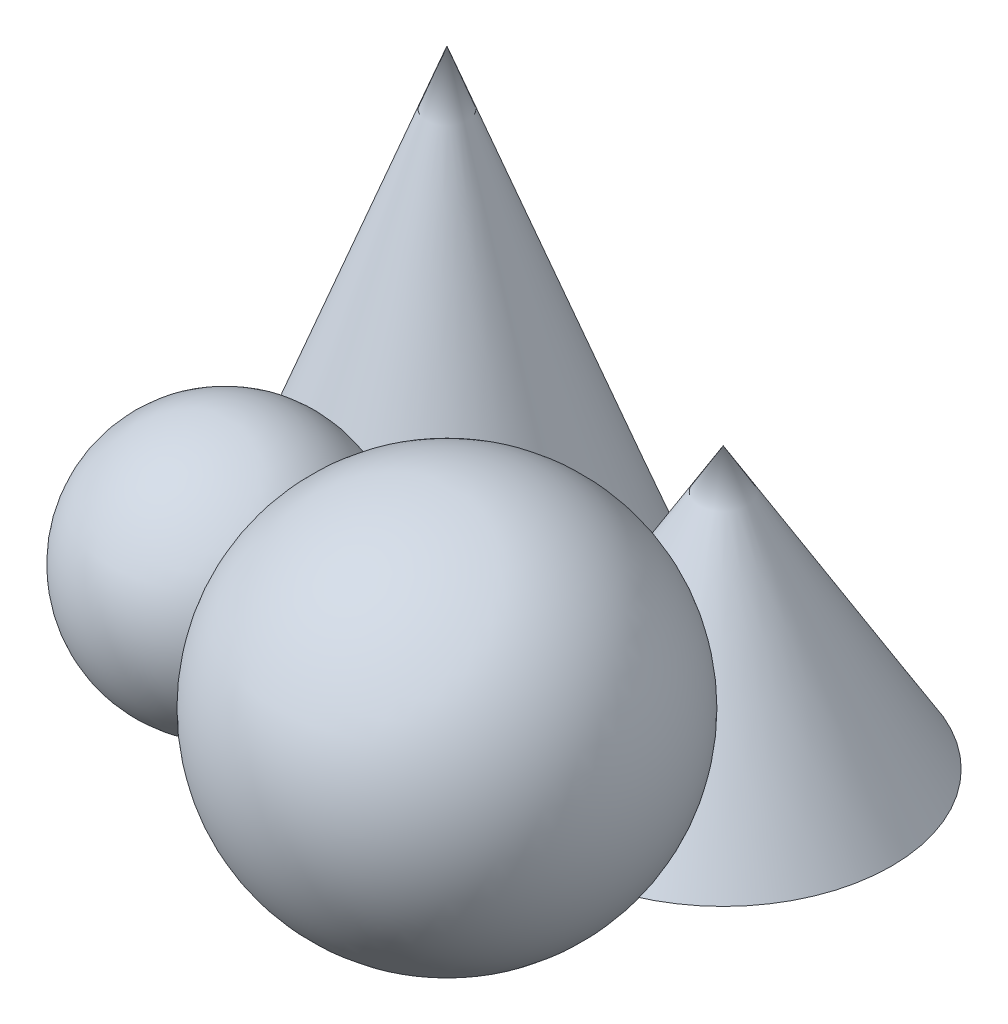
from build123d import *

# Parameters (mm, degrees)
SKETCH1_R = 30
SKETCH4_R = 30.84690874


with BuildPart() as part:
    # Sketch1 → ConeB section 0
    with BuildSketch(Plane(origin=(0, 0, 0), x_dir=(1, 0, 0), z_dir=(0, 1, 0)), mode=Mode.PRIVATE) as coneb_s0:
        Circle(SKETCH1_R)
    loft([Vertex(0, 80, 0), coneb_s0.sketch])


with BuildPart() as body_2:
    # Sketch3 → SphereA (revolve)
    with BuildSketch(Plane.XY.offset(60.1040764)):
        with BuildLine():
            Line((60.1040764, 70), (60.1040764, 0))
            ThreePointArc((60.1040764, 0), (95.1040764, 35), (60.1040764, 70))
        make_face()
    revolve(axis=Axis((60.1040764, 70, 60.1040764), (0, -1, 0)))


with BuildPart() as body_3:
    # Sketch4 → ConeD section 0
    with BuildSketch(Plane(origin=(0, 0, 0), x_dir=(1, 0, 0), z_dir=(0, 1, 0)), mode=Mode.PRIVATE) as coned_s0:
        with Locations((60.1040764, -9.45621576)):
            Circle(SKETCH4_R)
    loft([coned_s0.sketch, Vertex(60.1040764, 51.33236066, 9.45621576)])


with BuildPart() as body_4:
    # Sketch6 → SphereC (revolve)
    with BuildSketch(Plane.XY.offset(45.74120625)):
        with BuildLine():
            Line((5.05797364, 46.23375526), (5.05797364, 0))
            ThreePointArc((5.05797364, 0), (28.17485127, 23.11687763), (5.05797364, 46.23375526))
        make_face()
    revolve(axis=Axis((5.05797364, 46.23375526, 45.74120625), (0, -1, 0)))


solid = Compound([part.part, body_2.part, body_3.part, body_4.part])
